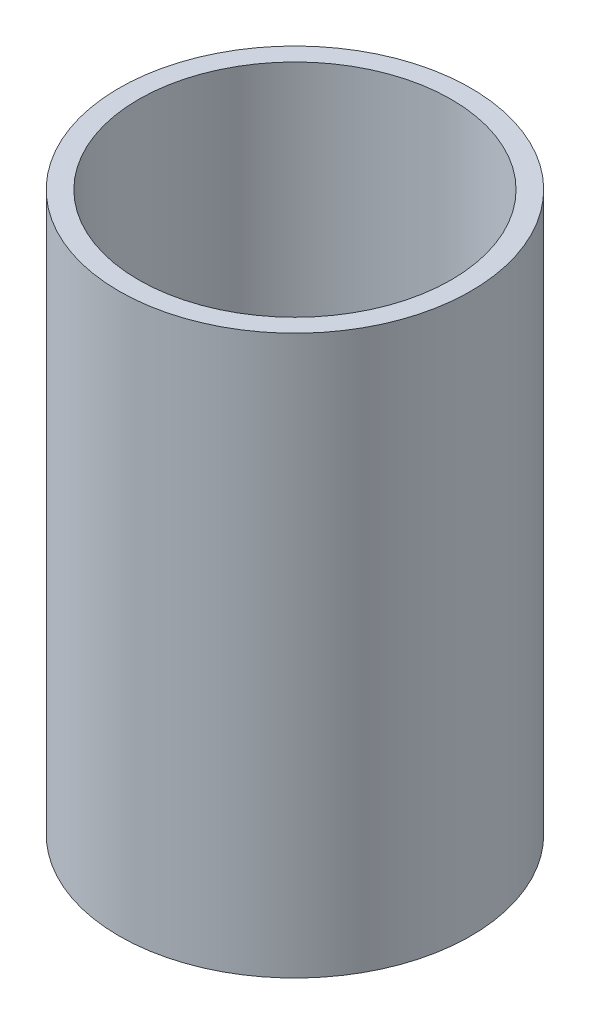
from build123d import *

# Parameters (mm, degrees)
ESQUISSE1_R             = 31.5
BOSS_EXTRU_1_DEPTH      = 100
ENL_V_MAT_EXTRU_1_REACH = 102
ESQUISSE2_R             = 28


with BuildPart() as part:
    # Esquisse1 → Boss.-Extru.1 (new body)
    with BuildSketch(Plane(origin=(0, 0, 0), x_dir=(1, 0, 0), z_dir=(0, 1, 0))):
        Circle(ESQUISSE1_R)
    extrude(amount=BOSS_EXTRU_1_DEPTH)

    # Esquisse2 → Enlèv. mat.-Extru.1 (cut, up to next)
    with BuildSketch(Plane(origin=(0, 100, 0), x_dir=(1, 0, 0), z_dir=(0, 1, 0)), mode=Mode.PRIVATE) as enl_v_mat_extru_1_sk1:
        Circle(ESQUISSE2_R)
    enl_v_mat_extru_1_tool1 = extrude(enl_v_mat_extru_1_sk1.sketch, amount=-ENL_V_MAT_EXTRU_1_REACH, mode=Mode.PRIVATE) & part.part
    add(enl_v_mat_extru_1_tool1.solids().sort_by_distance((0, 100, 0))[0], mode=Mode.SUBTRACT)


solid = part.part
